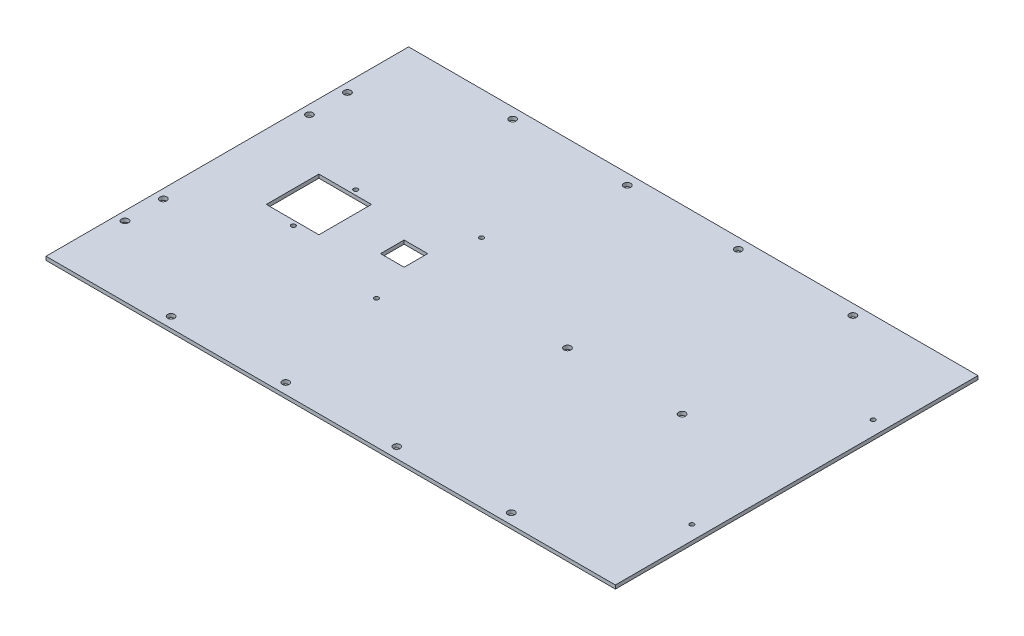
from build123d import *

# Parameters (mm, degrees)
SKETCH1_W                    = 199.39
SKETCH1_H                    = 127
BOSS_EXTRUDE1_DEPTH          = 2.54
F_11_0_191_DIAMETER_HOLE1_D  = 4.8514
F_11_0_191_DIAMETER_HOLE2_D  = 4.8514
SKETCH8_W                    = 36.83
SKETCH8_H                    = 18.415
SKETCH8_W_2                  = 16.51
SKETCH8_H_2                  = 8.255
CUT_EXTRUDE1_DEPTH           = 2.54
F_11_0_191_DIAMETER_HOLE3_D  = 4.8514
F_31_0_12_DIAMETER_HOLE2_D   = 3.048
F_31_0_12_DIAMETER_HOLE3_D   = 3.048
F_1_8_0_125_DIAMETER_HOLE1_D = 3.048


with BuildPart() as part:
    # Sketch1 → Boss-Extrude1 (new body)
    with BuildSketch(Plane(origin=(0, 0, 0), x_dir=(1, 0, 0), z_dir=(0, 1, 0))):
        with Locations((-99.695, 0)):
            Rectangle(SKETCH1_W, SKETCH1_H)
        with Locations((99.695, 0)):
            Rectangle(SKETCH1_W, SKETCH1_H)
    boss_extrude1 = extrude(amount=BOSS_EXTRUDE1_DEPTH)

    # #11 (0.191) Diameter Hole1 (through all)
    with Locations(Plane(origin=(0, 2.54, 0), x_dir=(1, 0, 0), z_dir=(0, 1, 0))):
        with Locations((-193.167, -14.4018), (-193.04, 12.3444)):
            f_11_0_191_diameter_hole1 = Hole(F_11_0_191_DIAMETER_HOLE1_D / 2)

    # #11 (0.191) Diameter Hole2 (through all)
    with Locations(Plane(origin=(0, 2.54, 0), x_dir=(1, 0, 0), z_dir=(0, 1, 0))):
        with Locations((-119.126, -56.127777467), (-38.862, -56.127777467), (38.862, -56.127777467), (119.126, -56.127777467)):
            f_11_0_191_diameter_hole2 = Hole(F_11_0_191_DIAMETER_HOLE2_D / 2)

    # Sketch8 → Cut-Extrude1 (cut)
    with BuildSketch(Plane(origin=(0, 2.54, 0), x_dir=(1, 0, 0), z_dir=(0, 1, 0))):
        with Locations((-135.255, 54.2925)):
            Rectangle(SKETCH8_W, SKETCH8_H)
        with Locations((-75.565, 59.3725)):
            Rectangle(SKETCH8_W_2, SKETCH8_H_2)
    cut_extrude1 = extrude(amount=-CUT_EXTRUDE1_DEPTH, mode=Mode.SUBTRACT)

    # Mirror6: Boss-Extrude1, #11 (0.191) Diameter Hole1, #11 (0.191) Diameter Hole2, Cut-Extrude1 across plane
    add(boss_extrude1.mirror(Plane(origin=(0, 2.54, -63.5), x_dir=(1, 0, 0), z_dir=(0, 0, -1))))
    add(f_11_0_191_diameter_hole1.mirror(Plane(origin=(0, 2.54, -63.5), x_dir=(1, 0, 0), z_dir=(0, 0, -1))), mode=Mode.SUBTRACT)
    add(f_11_0_191_diameter_hole2.mirror(Plane(origin=(0, 2.54, -63.5), x_dir=(1, 0, 0), z_dir=(0, 0, -1))), mode=Mode.SUBTRACT)
    add(cut_extrude1.mirror(Plane(origin=(0, 2.54, -63.5), x_dir=(1, 0, 0), z_dir=(0, 0, -1))), mode=Mode.SUBTRACT)

    # #11 (0.191) Diameter Hole3 (through all)
    with Locations(Plane(origin=(0, 2.54, 0), x_dir=(1, 0, 0), z_dir=(0, 1, 0))):
        with Locations((119.126, 63.5), (38.862, 63.5)):
            Hole(F_11_0_191_DIAMETER_HOLE3_D / 2)

    # #31 (0.12) Diameter Hole2 (through all)
    with Locations(Plane(origin=(0, 2.54, 0), x_dir=(1, 0, 0), z_dir=(0, 1, 0))):
        with Locations((-131.318, 41.656), (-131.318, 85.344)):
            Hole(F_31_0_12_DIAMETER_HOLE2_D / 2)

    # #31 (0.12) Diameter Hole3 (through all)
    with Locations(Plane(origin=(0, 2.54, 0), x_dir=(1, 0, 0), z_dir=(0, 1, 0))):
        with Locations((-58.166, 100.33), (-58.166, 26.67)):
            Hole(F_31_0_12_DIAMETER_HOLE3_D / 2)

    # 1/8 (0.125) Diameter Hole1 (through all)
    with Locations(Plane(origin=(0, 2.54, 0), x_dir=(1, 0, 0), z_dir=(0, 1, 0))):
        with Locations((189.484, 0), (189.484, 127)):
            Hole(F_1_8_0_125_DIAMETER_HOLE1_D / 2)


solid = part.part
